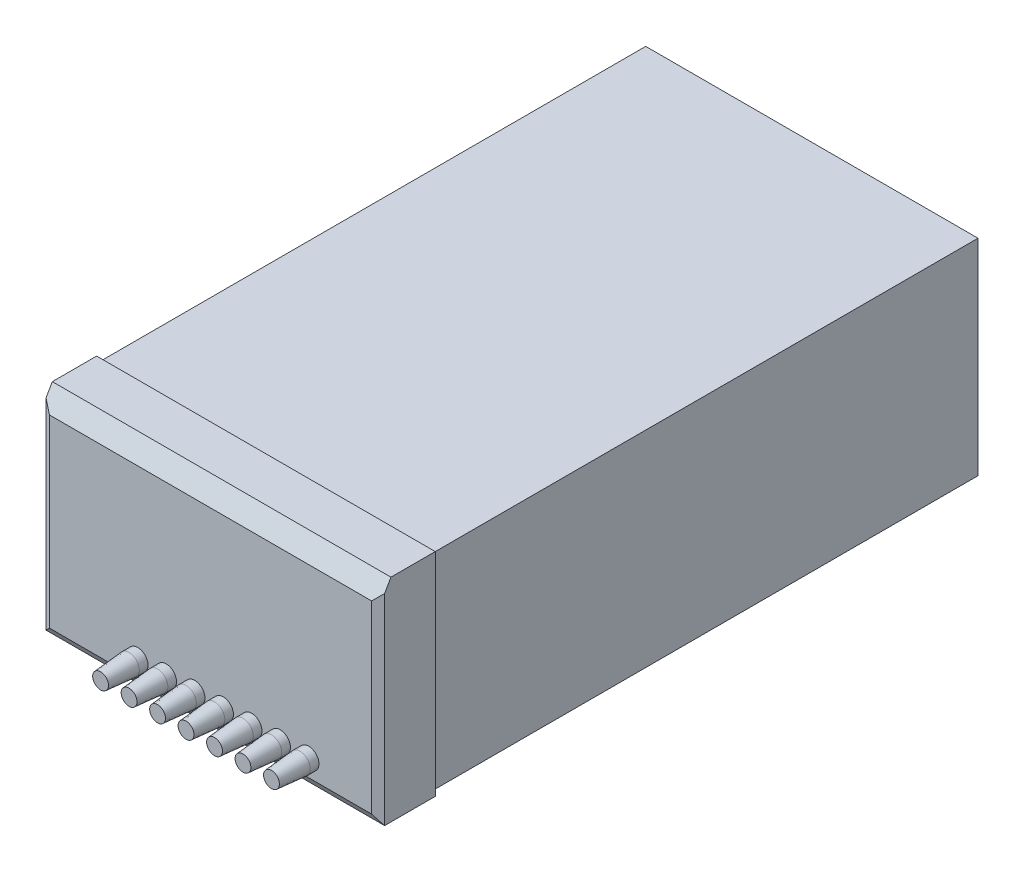
from build123d import *

# Parameters (mm, degrees)
SKETCH1_W             = 210
SKETCH1_H             = 130
BOSS_EXTRUDE1_DEPTH   = 345
SKETCH2_W             = 214
SKETCH2_H             = 134
BOSS_EXTRUDE2_DEPTH   = 35
CHAMFER2_SIZE         = 7
CHAMFER2_SIZE2        = 12.124355653
CHAMFER3_SIZE         = 3
CHAMFER3_SIZE2        = 5.196152423
CHAMFER3_PART_2_SIZE  = 3
CHAMFER3_PART_2_SIZE2 = 5.196152423
CHAMFER3_PART_3_SIZE  = 3
CHAMFER3_PART_3_SIZE2 = 5.196152423
SKETCH3_R             = 6.5
BOSS_EXTRUDE3_DEPTH   = 5.5
BOSS_EXTRUDE3_2_DEPTH = 5.5
BOSS_EXTRUDE3_3_DEPTH = 5.5
BOSS_EXTRUDE3_4_DEPTH = 5.5
BOSS_EXTRUDE3_5_DEPTH = 5.5
BOSS_EXTRUDE3_6_DEPTH = 5.5
BOSS_EXTRUDE3_7_DEPTH = 5.5
SKETCH5_R             = 6.5
SKETCH6_R             = 5
LPATTERN1_COUNT       = 7
LPATTERN1_PITCH       = 18


with BuildPart() as part:
    # Sketch1 → Boss-Extrude1 (new body)
    with BuildSketch(Plane.XY):
        Rectangle(SKETCH1_W, SKETCH1_H)
    extrude(amount=-BOSS_EXTRUDE1_DEPTH)


with BuildPart() as body_2:
    # Sketch2 → Boss-Extrude2 (new body)
    with BuildSketch(Plane.XY):
        Rectangle(SKETCH2_W, SKETCH2_H)
    extrude(amount=BOSS_EXTRUDE2_DEPTH)

    # Chamfer2
    chamfer2_edges = [body_2.edges().sort_by_distance(p)[0] for p in [
        (0, 67, 35),
    ]]
    chamfer2_side = [body_2.faces().sort_by_distance(p)[0] for p in [
        (0, 67, 17.5),
    ]]
    chamfer(chamfer2_edges, length=CHAMFER2_SIZE, length2=CHAMFER2_SIZE2, reference=chamfer2_side[0])

    # Chamfer3
    chamfer3_edges = [body_2.edges().sort_by_distance(p)[0] for p in [
        (-107, -6.062177826, 35),
    ]]
    chamfer3_side = [body_2.faces().sort_by_distance(p)[0] for p in [
        (-107, -0.574851894, 17.361518613),
    ]]
    chamfer(chamfer3_edges, length=CHAMFER3_SIZE, length2=CHAMFER3_SIZE2, reference=chamfer3_side[0])

    # Chamfer3 part 2
    chamfer3_part_2_edges = [body_2.edges().sort_by_distance(p)[0] for p in [
        (0, -67, 35),
    ]]
    chamfer3_part_2_side = [body_2.faces().sort_by_distance(p)[0] for p in [
        (0, -67, 17.5),
    ]]
    chamfer(chamfer3_part_2_edges, length=CHAMFER3_PART_2_SIZE, length2=CHAMFER3_PART_2_SIZE2, reference=chamfer3_part_2_side[0])

    # Chamfer3 part 3
    chamfer3_part_3_edges = [body_2.edges().sort_by_distance(p)[0] for p in [
        (107, -6.062177826, 35),
    ]]
    chamfer3_part_3_side = [body_2.faces().sort_by_distance(p)[0] for p in [
        (107, -0.574851894, 17.361518613),
    ]]
    chamfer(chamfer3_part_3_edges, length=CHAMFER3_PART_3_SIZE, length2=CHAMFER3_PART_3_SIZE2, reference=chamfer3_part_3_side[0])


with BuildPart() as body_3:
    # Sketch3 → Boss-Extrude3 (new body)
    with BuildSketch(Plane.XY.offset(35)):
        with Locations((-46, -51)):
            Circle(SKETCH3_R)
    extrude(amount=BOSS_EXTRUDE3_DEPTH)

    # Sketch5 → Loft1 section 0
    with BuildSketch(Plane.XY.offset(40.5)):
        with Locations((-46, -51)):
            Circle(SKETCH5_R)
    # Sketch6 → Loft1 section 1
    with BuildSketch(Plane.XY.offset(58.5)):
        with Locations((-46, -51)):
            Circle(SKETCH6_R)
    loft1 = loft()


with BuildPart() as body_4:
    # Sketch3 → Boss-Extrude3 2 (new body)
    with BuildSketch(Plane.XY.offset(35)):
        with Locations((-28, -51)):
            Circle(SKETCH3_R)
    extrude(amount=BOSS_EXTRUDE3_2_DEPTH)



with BuildPart() as body_5:
    # Sketch3 → Boss-Extrude3 3 (new body)
    with BuildSketch(Plane.XY.offset(35)):
        with Locations((-10, -51)):
            Circle(SKETCH3_R)
    extrude(amount=BOSS_EXTRUDE3_3_DEPTH)


with BuildPart() as body_6:
    # Sketch3 → Boss-Extrude3 4 (new body)
    with BuildSketch(Plane.XY.offset(35)):
        with Locations((8, -51)):
            Circle(SKETCH3_R)
    extrude(amount=BOSS_EXTRUDE3_4_DEPTH)


with BuildPart() as body_7:
    # Sketch3 → Boss-Extrude3 5 (new body)
    with BuildSketch(Plane.XY.offset(35)):
        with Locations((26, -51)):
            Circle(SKETCH3_R)
    extrude(amount=BOSS_EXTRUDE3_5_DEPTH)


with BuildPart() as body_8:
    # Sketch3 → Boss-Extrude3 6 (new body)
    with BuildSketch(Plane.XY.offset(35)):
        with Locations((44, -51)):
            Circle(SKETCH3_R)
    extrude(amount=BOSS_EXTRUDE3_6_DEPTH)


with BuildPart() as body_9:
    # Sketch3 → Boss-Extrude3 7 (new body)
    with BuildSketch(Plane.XY.offset(35)):
        with Locations((62, -51)):
            Circle(SKETCH3_R)
    extrude(amount=BOSS_EXTRUDE3_7_DEPTH)


with BuildPart() as body_4_1:
    add(body_4.part)

    add(body_5.part)  # LPattern1 merges body 5

    add(body_6.part)  # LPattern1 merges body 6

    add(body_7.part)  # LPattern1 merges body 7

    add(body_8.part)  # LPattern1 merges body 8

    add(body_9.part)  # LPattern1 merges body 9
    # LPattern1: Loft1 ×7
    with Locations(*[(i * LPATTERN1_PITCH, 0, 0) for i in range(1, LPATTERN1_COUNT)]):
        add(loft1)


solid = Compound([part.part, body_2.part, body_3.part, body_4_1.part])
